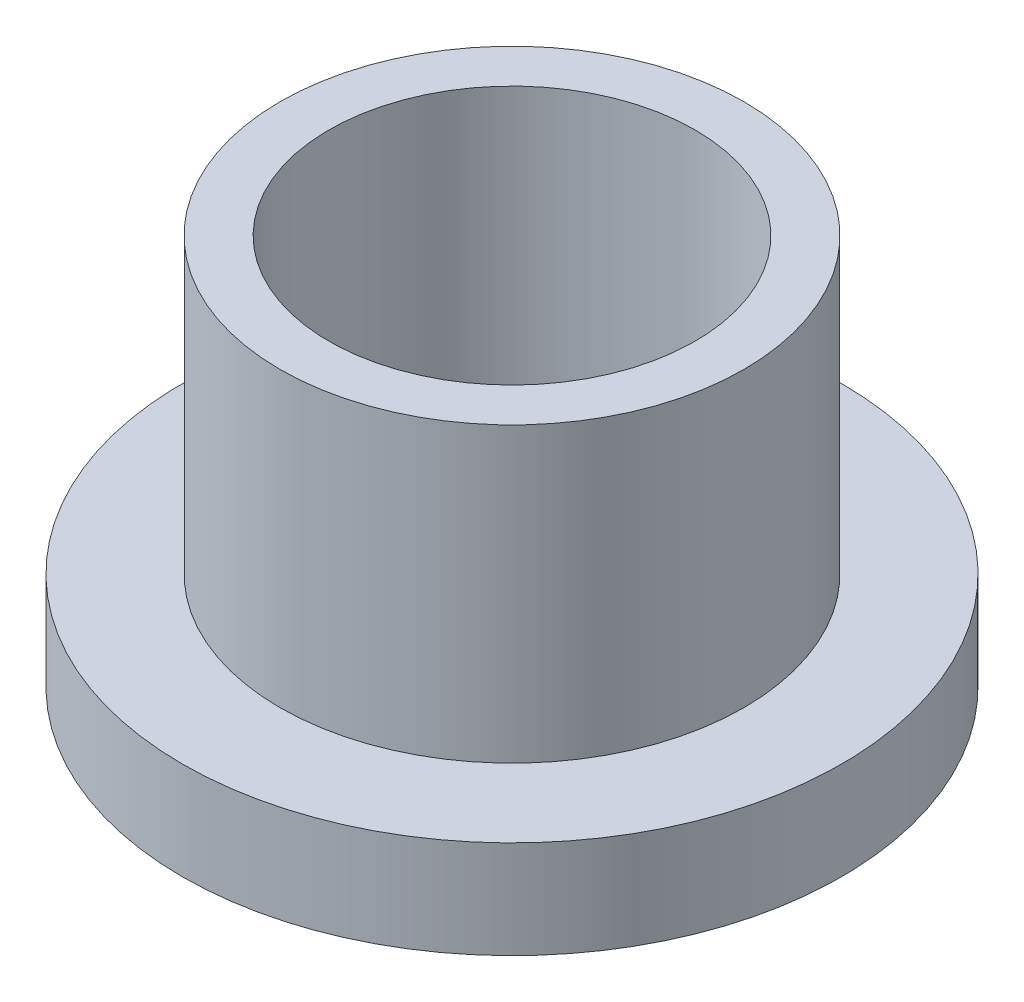
from build123d import *

# Parameters (mm, degrees)
CHAMFER1_SIZE = 0.2


with BuildPart() as part:
    # Sketch1 → Revolve1 (revolve)
    with BuildSketch(Plane.XY):
        Polygon((1.5, 0), (2.7, 0), (2.7, 0.8), (1.9, 0.8), (1.9, 3.2), (1.5, 3.2), align=None)
    revolve(axis=Axis((0, 0, 0), (0, 1, 0)))

    # Chamfer1
    chamfer1_edges = [part.edges().sort_by_distance(p)[0] for p in [
        (-1.5, 0, 0),
    ]]
    chamfer(chamfer1_edges, length=CHAMFER1_SIZE)


solid = part.part
